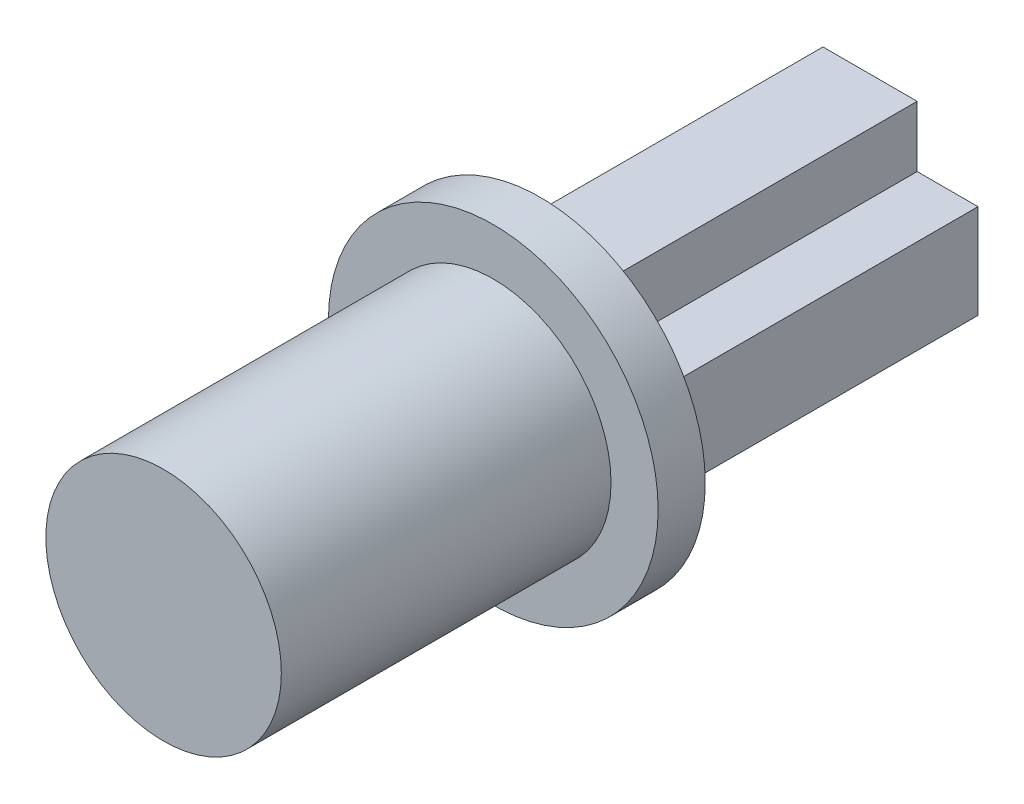
from build123d import *

# Parameters (mm, degrees)
BOSS_EXTRUDE1_DEPTH = 7
SKETCH2_R           = 3.5
BOSS_EXTRUDE2_DEPTH = 1
SKETCH3_R           = 2.5
BOSS_EXTRUDE3_DEPTH = 7


with BuildPart() as part:
    # Sketch1 → Boss-Extrude1 (new body)
    with BuildSketch(Plane.XY):
        Polygon((2.291287847, -1.026567818), (1, -1.026567818), (1, -2.317855665), (-1, -2.317855665), (-1, -1.026567818), (-2.291287847, -1.026567818), (-2.291287847, 0.973432182), (-1, 0.973432182), (-1, 2.26472003), (1, 2.26472003), (1, 0.973432182), (2.291287847, 0.973432182), align=None)
    extrude(amount=BOSS_EXTRUDE1_DEPTH)

    # Sketch2 → Boss-Extrude2 (add)
    with BuildSketch(Plane.XY.offset(7)):
        Circle(SKETCH2_R)
    extrude(amount=BOSS_EXTRUDE2_DEPTH)

    # Sketch3 → Boss-Extrude3 (add)
    with BuildSketch(Plane.XY.offset(8)):
        Circle(SKETCH3_R)
    extrude(amount=BOSS_EXTRUDE3_DEPTH)


solid = part.part
